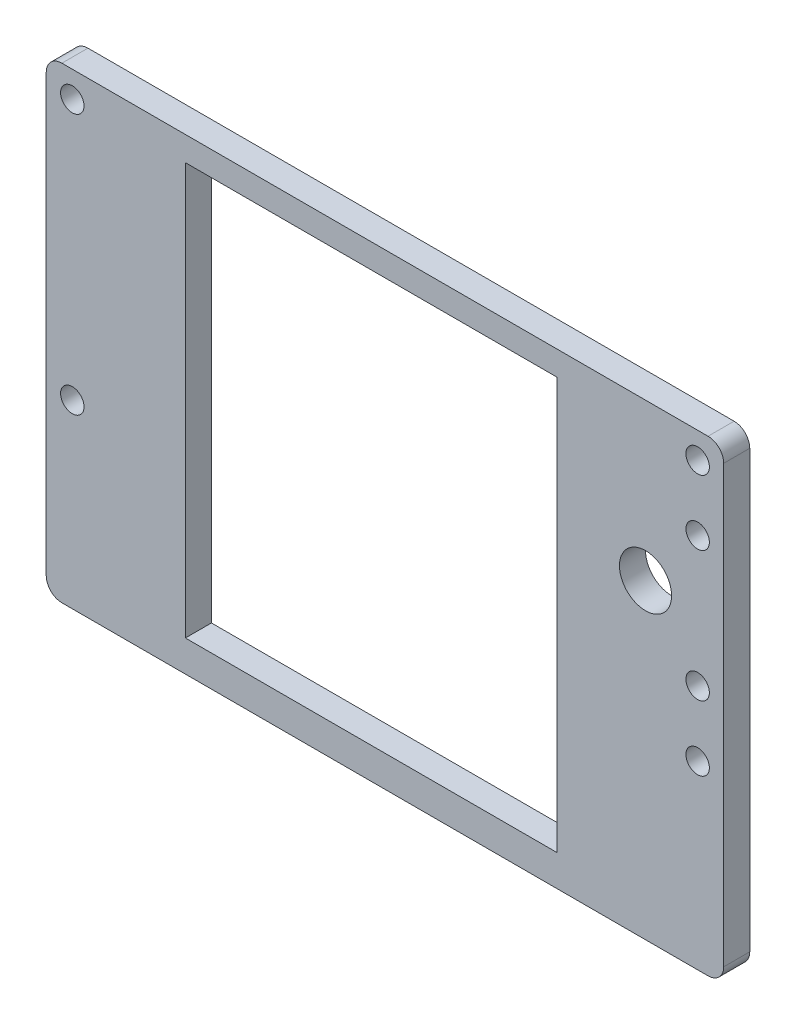
from build123d import *

# Parameters (mm, degrees)
SKETCH1_W           = 130
SKETCH1_H           = 89.679378249
SKETCH1_R           = 2.25
SKETCH1_W_2         = 71.3
SKETCH1_H_2         = 79
BOSS_EXTRUDE1_DEPTH = 5
FILLET1_R           = 3
SKETCH2_R           = 5
CUT_EXTRUDE1_DEPTH  = 5
SKETCH3_R           = 2.25
CUT_EXTRUDE2_DEPTH  = 5


with BuildPart() as part:
    # Sketch1 → Boss-Extrude1 (new body)
    with BuildSketch(Plane.XY):
        with Locations((65, -44.839689125)):
            Rectangle(SKETCH1_W, SKETCH1_H)
        with Locations((125, -5)):
            Circle(SKETCH1_R, mode=Mode.SUBTRACT)
        with Locations((125, -55)):
            Circle(SKETCH1_R, mode=Mode.SUBTRACT)
        with Locations((5, -55)):
            Circle(SKETCH1_R, mode=Mode.SUBTRACT)
        with Locations((5, -5)):
            Circle(SKETCH1_R, mode=Mode.SUBTRACT)
        with Locations((62.35, -44.179378249)):
            Rectangle(SKETCH1_W_2, SKETCH1_H_2, mode=Mode.SUBTRACT)
    extrude(amount=BOSS_EXTRUDE1_DEPTH)

    # Fillet1
    fillet1_edges = [part.edges().sort_by_distance(p)[0] for p in [
        (0, 0, 2.5),
        (130, 0, 2.5),
        (130, -89.679378249, 2.5),
        (0, -89.679378249, 2.5),
    ]]
    fillet(fillet1_edges, radius=FILLET1_R)

    # Sketch2 → Cut-Extrude1 (cut)
    with BuildSketch(Plane(origin=(0, 0, 0), x_dir=(-1, 0, 0), z_dir=(0, 0, -1))):
        with Locations((-115, -30)):
            Circle(SKETCH2_R)
    extrude(amount=-CUT_EXTRUDE1_DEPTH, mode=Mode.SUBTRACT)

    # Sketch3 → Cut-Extrude2 (cut)
    with BuildSketch(Plane.XY.offset(5)):
        with Locations((125, -42.5)):
            Circle(SKETCH3_R)
        with Locations((125, -17.5)):
            Circle(SKETCH3_R)
    extrude(amount=-CUT_EXTRUDE2_DEPTH, mode=Mode.SUBTRACT)


solid = part.part
